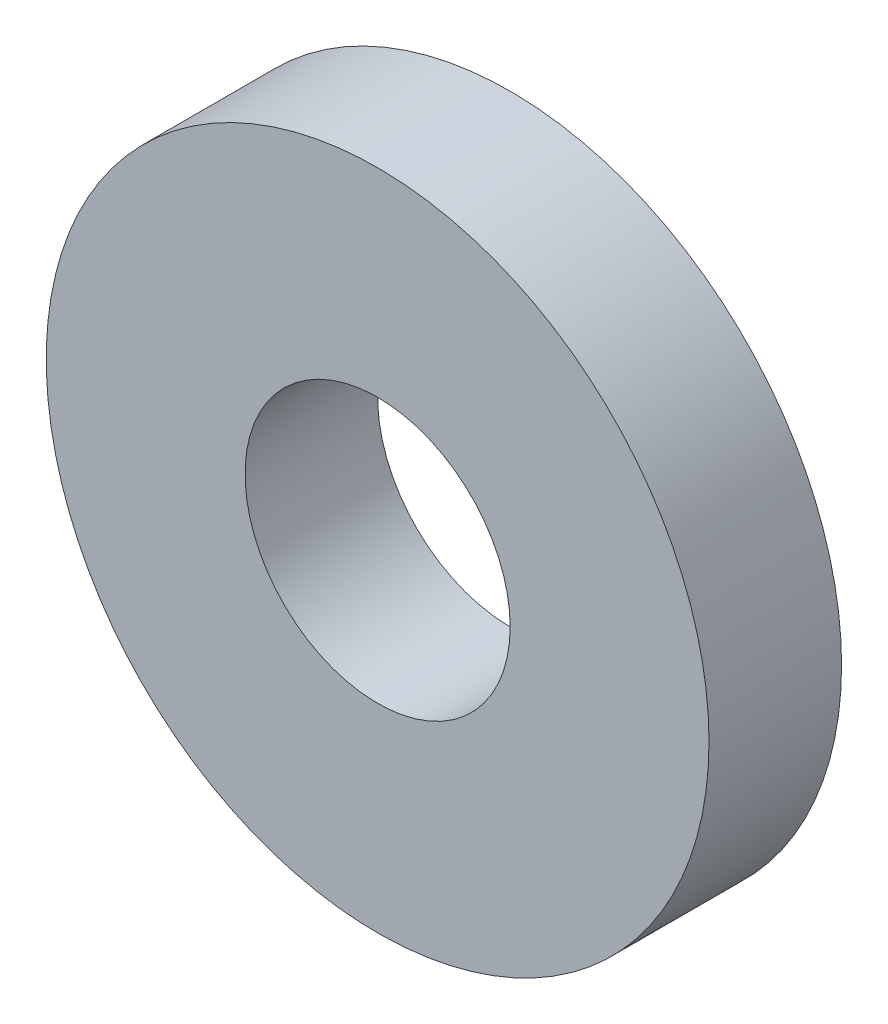
from build123d import *

# Parameters (mm, degrees)
SKETCH1_R           = 12.5
BOSS_EXTRUDE3_DEPTH = 5
SKETCH5_R           = 5
CUT_EXTRUDE1_DEPTH  = 6


with BuildPart() as part:
    # Sketch1 → Boss-Extrude3 (new body)
    with BuildSketch(Plane.XY):
        Circle(SKETCH1_R)
    extrude(amount=BOSS_EXTRUDE3_DEPTH)

    # Sketch5 → Cut-Extrude1 (cut, through all)
    with BuildSketch(Plane.XY.offset(5)):
        Circle(SKETCH5_R)
    extrude(amount=-CUT_EXTRUDE1_DEPTH, mode=Mode.SUBTRACT)


solid = part.part
